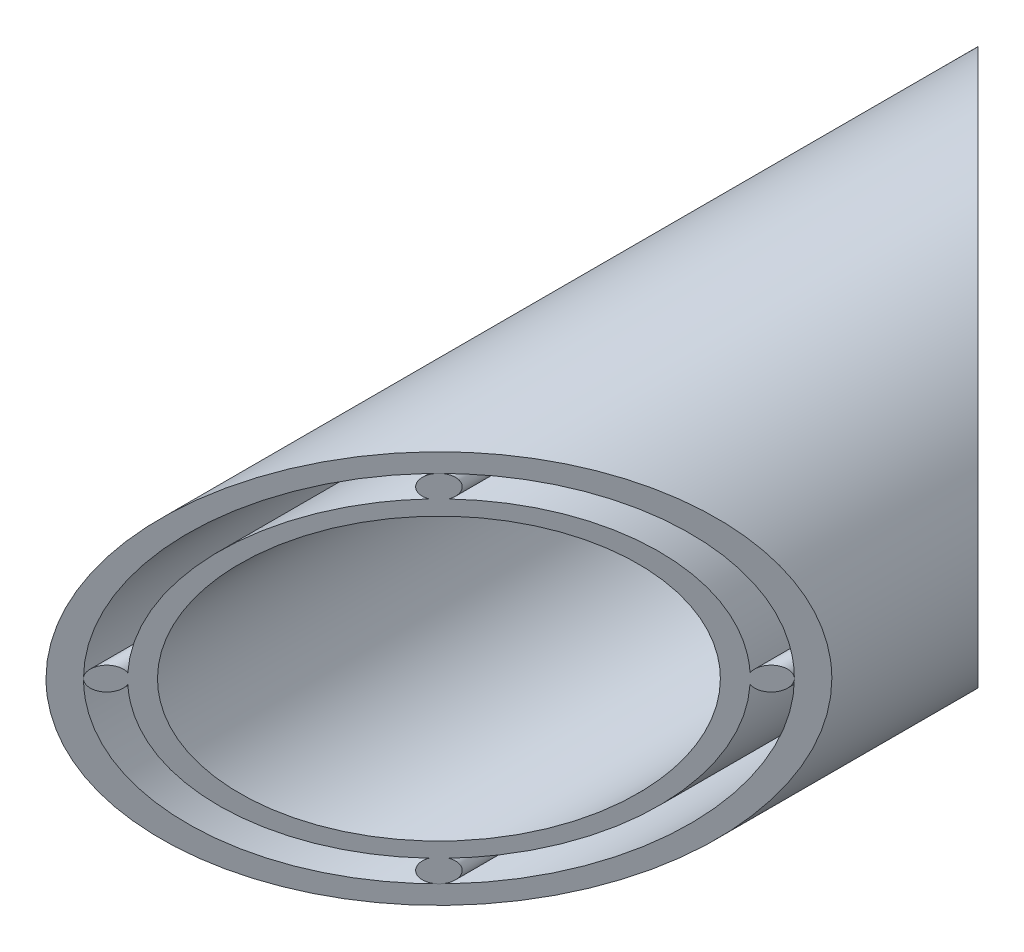
from build123d import *

# Parameters (mm, degrees)
SKETCH1_R             = 21.08
BOSS_EXTRUDE2_DEPTH   = 50
SKETCH1_R_2           = 15.1
BOSS_EXTRUDE2_2_DEPTH = 50
CUT_EXTRUDE1_START    = -21.08
CUT_EXTRUDE1_DEPTH    = 42.16


with BuildPart() as part:
    # Sketch1 → Boss-Extrude2 (new body, symmetric)
    with BuildSketch(Plane.XY):
        Circle(SKETCH1_R)
        with BuildLine():
            ThreePointArc((19.07, 0), (13.484526, -13.484526), (0, -19.07))
            ThreePointArc((0, -19.07), (-13.484526, -13.484526), (-19.07, 0))
            ThreePointArc((-19.07, 0), (-13.484526, 13.484526), (0, 19.07))
            ThreePointArc((0, 19.07), (13.484526, 13.484526), (19.07, 0))
        make_face(mode=Mode.SUBTRACT)
    extrude(amount=BOSS_EXTRUDE2_DEPTH, both=True)


with BuildPart() as body_2:
    # Sketch1 → Boss-Extrude2 2 (new body, symmetric)
    with BuildSketch(Plane.XY):
        with BuildLine():
            ThreePointArc((16.691355, -0.537272), (18.095403, -1.219284), (19.07, 0))
            ThreePointArc((19.07, 0), (18.095403, 1.219284), (16.691355, 0.537272))
            ThreePointArc((16.691355, 0.537272), (11.808683, 11.808683), (0.537272, 16.691355))
            ThreePointArc((0.537272, 16.691355), (1.219284, 18.095403), (0, 19.07))
            ThreePointArc((0, 19.07), (-1.219284, 18.095403), (-0.537272, 16.691355))
            ThreePointArc((-0.537272, 16.691355), (-11.808683, 11.808683), (-16.691355, 0.537272))
            ThreePointArc((-16.691355, 0.537272), (-18.095403, 1.219284), (-19.07, 0))
            ThreePointArc((-19.07, 0), (-18.095403, -1.219284), (-16.691355, -0.537272))
            ThreePointArc((-16.691355, -0.537272), (-11.808683, -11.808683), (-0.537272, -16.691355))
            ThreePointArc((-0.537272, -16.691355), (-1.219284, -18.095403), (0, -19.07))
            ThreePointArc((0, -19.07), (1.219284, -18.095403), (0.537272, -16.691355))
            ThreePointArc((0.537272, -16.691355), (11.808683, -11.808683), (16.691355, -0.537272))
        make_face()
        Circle(SKETCH1_R_2, mode=Mode.SUBTRACT)
    extrude(amount=BOSS_EXTRUDE2_2_DEPTH, both=True)


with BuildPart() as cut_extrude1_tool:
    # Sketch2 → Cut-Extrude1 (new body)
    with BuildSketch(Plane(origin=(0, 0, 0), x_dir=(1, 0, 0), z_dir=(0, 1, 0)).offset(CUT_EXTRUDE1_START)):
        Polygon((21.08, 50), (-21.08, 50), (21.08, 7.84), align=None)
        Polygon((21.08, -50), (-21.08, -50), (21.08, -7.84), align=None)
    extrude(amount=CUT_EXTRUDE1_DEPTH)


with BuildPart() as part_1:
    add(part.part)

    # Cut-Extrude1: cut by cut_extrude1_tool
    add(cut_extrude1_tool.part, mode=Mode.SUBTRACT)


with BuildPart() as body_2_1:
    add(body_2.part)

    # Cut-Extrude1: cut by cut_extrude1_tool
    add(cut_extrude1_tool.part, mode=Mode.SUBTRACT)


solid = Compound([part_1.part, body_2_1.part])
